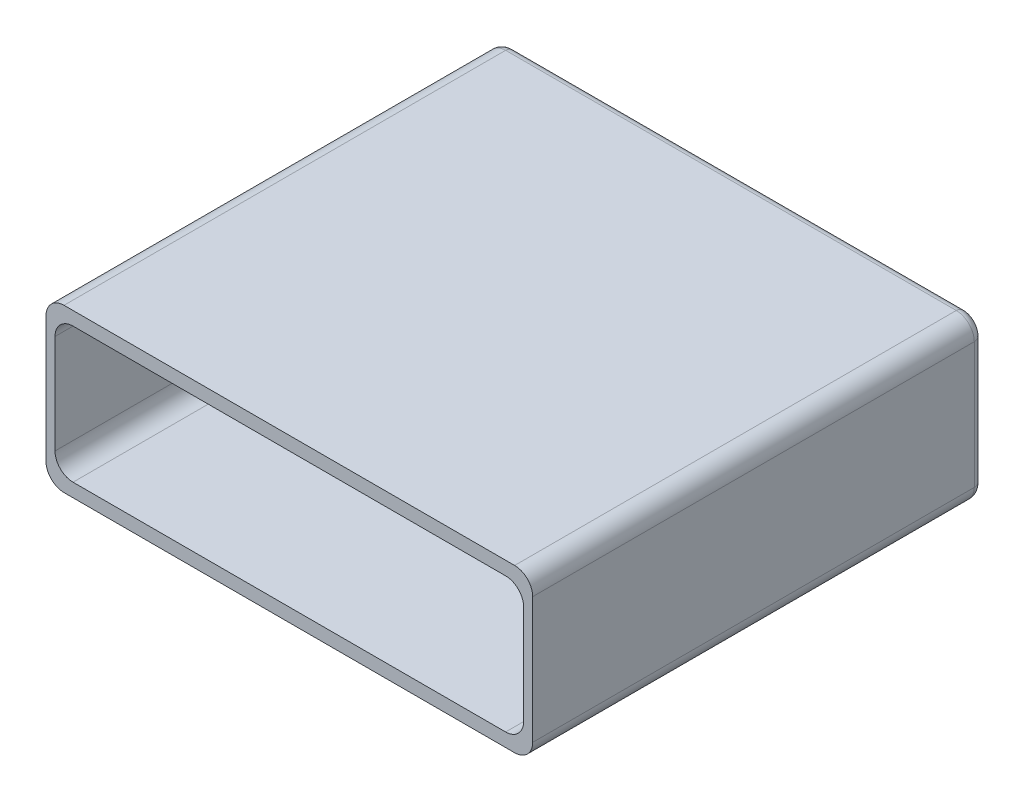
from build123d import *

# Parameters (mm, degrees)
BOSS_EXTRUDE1_DEPTH = 50
CUT_EXTRUDE1_DEPTH  = 48
FILLET1_R           = 1


with BuildPart() as part:
    # Sketch1 → Boss-Extrude1 (new body)
    with BuildSketch(Plane.XY):
        with BuildLine():
            Line((25, 9), (-25, 9))
            ThreePointArc((-25, 9), (-26.414213562, 8.414213562), (-27, 7))
            Line((-27, 7), (-27, -7))
            ThreePointArc((-27, -7), (-26.414213562, -8.414213562), (-25, -9))
            Line((-25, -9), (25, -9))
            ThreePointArc((25, -9), (26.414213562, -8.414213562), (27, -7))
            Line((27, -7), (27, 7))
            ThreePointArc((27, 7), (26.414213562, 8.414213562), (25, 9))
        make_face()
    extrude(amount=BOSS_EXTRUDE1_DEPTH)

    # Sketch2 → Cut-Extrude1 (cut)
    with BuildSketch(Plane.XY.offset(50)):
        with BuildLine():
            Line((24, -7.5), (-24, -7.5))
            ThreePointArc((-24, -7.5), (-25.414213562, -6.914213562), (-26, -5.5))
            Line((-26, -5.5), (-26, 5.5))
            ThreePointArc((-26, 5.5), (-25.414213562, 6.914213562), (-24, 7.5))
            Line((-24, 7.5), (24, 7.5))
            ThreePointArc((24, 7.5), (25.414213562, 6.914213562), (26, 5.5))
            Line((26, 5.5), (26, -5.5))
            ThreePointArc((26, -5.5), (25.414213562, -6.914213562), (24, -7.5))
        make_face()
    extrude(amount=-CUT_EXTRUDE1_DEPTH, mode=Mode.SUBTRACT)

    # Fillet1
    fillet1_edges = [part.edges().sort_by_distance(p)[0] for p in [
        (0, -9, 0),
        (-26.414213562, -8.414213562, 0),
        (-27, 0, 0),
        (-26.414213562, 8.414213562, 0),
        (0, 9, 0),
        (26.414213562, 8.414213562, 0),
        (27, 0, 0),
        (26.414213562, -8.414213562, 0),
    ]]
    fillet(fillet1_edges, radius=FILLET1_R)


solid = part.part
